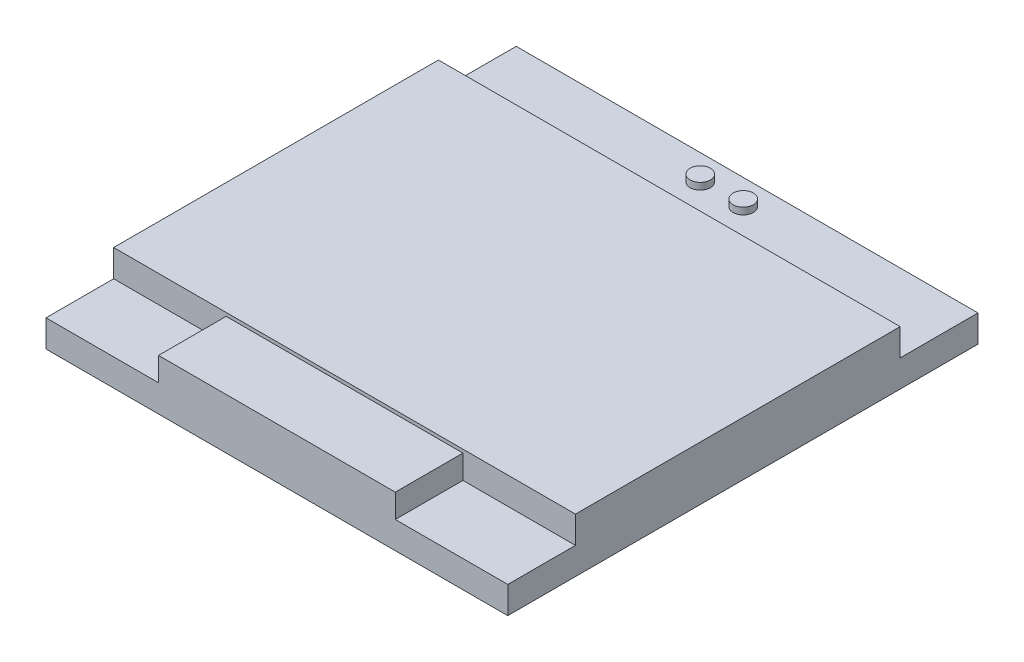
from build123d import *

# Parameters (mm, degrees)
SKETCH_1_W           = 27.3
SKETCH_1_H           = 27.8
EXTRUDE_1_DEPTH      = 1.6
SKETCH_2_R           = 0.6
EXTRUDE_2_DEPTH      = 4.9
EXTRUDE_2_DEPTH_BACK = 2
SKETCH_3_W           = 27.3
SKETCH_3_H           = 19.2
EXTRUDE_3_DEPTH      = 1.6
SKETCH_4_W           = 14
SKETCH_4_H           = 4
EXTRUDE_4_DEPTH      = 1.4


with BuildPart() as part:
    # 草图1 → 凸台-拉伸1 (new body)
    with BuildSketch(Plane(origin=(0, 0, 0), x_dir=(1, 0, 0), z_dir=(0, 1, 0))):
        with Locations((13.65, 13.9)):
            Rectangle(SKETCH_1_W, SKETCH_1_H)
    extrude(amount=EXTRUDE_1_DEPTH)

    # 草图2 → 凸台-拉伸2 (add, two sides)
    with BuildSketch(Plane.XZ) as extrude_2_sk:
        with Locations((14.92, -26.3)):
            Circle(SKETCH_2_R)
        with Locations((12.38, -26.3)):
            Circle(SKETCH_2_R)
    extrude(amount=EXTRUDE_2_DEPTH)
    extrude(extrude_2_sk.sketch, amount=-EXTRUDE_2_DEPTH_BACK)

    # 草图3 → 凸台-拉伸3 (add)
    with BuildSketch(Plane(origin=(0, 1.6, 0), x_dir=(1, 0, 0), z_dir=(0, 1, 0))):
        with Locations((13.65, 13.6)):
            Rectangle(SKETCH_3_W, SKETCH_3_H)
    extrude(amount=EXTRUDE_3_DEPTH)

    # 草图4 → 凸台-拉伸4 (add)
    with BuildSketch(Plane(origin=(0, 1.6, 0), x_dir=(1, 0, 0), z_dir=(0, 1, 0))):
        with Locations((13.65, 2)):
            Rectangle(SKETCH_4_W, SKETCH_4_H)
    extrude(amount=EXTRUDE_4_DEPTH)


solid = part.part
